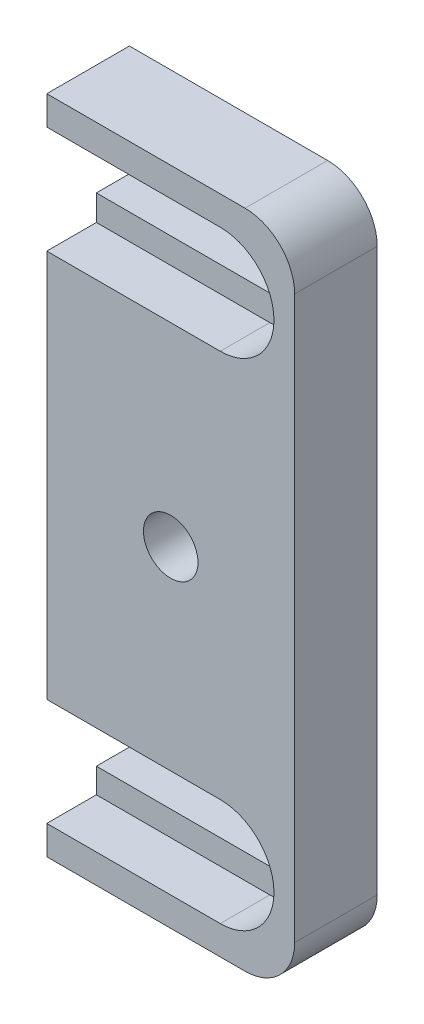
from build123d import *

# Parameters (mm, degrees)
SKETCH1_W                 = 15
SKETCH1_H                 = 40
BOSS_EXTRUDE1_DEPTH       = 5
CUT_EXTRUDE1_DEPTH        = 3
CUT_EXTRUDE2_DEPTH        = 3
CUT_EXTRUDE3_DEPTH        = 3
CUT_EXTRUDE4_DEPTH        = 6
F_4_CLEARANCE_HOLE1_D     = 3.3
F_4_CLEARANCE_HOLE1_DEPTH = 5
FILLET1_R                 = 3


with BuildPart() as part:
    # Sketch1 → Boss-Extrude1 (new body)
    with BuildSketch(Plane.XY.offset(5)):
        with Locations((7.5, -20)):
            Rectangle(SKETCH1_W, SKETCH1_H)
    extrude(amount=-BOSS_EXTRUDE1_DEPTH)

    # Sketch2 → Cut-Extrude1 (cut)
    with BuildSketch(Plane.XY.offset(5)):
        with BuildLine():
            Line((0, -8.25), (10.5, -8.25))
            ThreePointArc((10.5, -8.25), (13.75, -5), (10.5, -1.75))
            Line((10.5, -1.75), (0, -1.75))
            Line((0, -1.75), (0, -8.25))
        make_face()
    extrude(amount=-CUT_EXTRUDE1_DEPTH, mode=Mode.SUBTRACT)

    # Sketch3 → Cut-Extrude2 (cut, through all)
    with BuildSketch(Plane.XY.offset(2)):
        with BuildLine():
            Line((0, -3.3), (0, -6.7))
            Line((0, -6.7), (10.5, -6.7))
            ThreePointArc((10.5, -6.7), (12.2, -5), (10.5, -3.3))
            Line((10.5, -3.3), (0, -3.3))
        make_face()
    extrude(amount=-CUT_EXTRUDE2_DEPTH, mode=Mode.SUBTRACT)

    # Sketch4 → Cut-Extrude3 (cut)
    with BuildSketch(Plane.XY.offset(5)):
        with BuildLine():
            Line((0, -38.25), (10.5, -38.25))
            ThreePointArc((10.5, -38.25), (13.75, -35), (10.5, -31.75))
            Line((10.5, -31.75), (0, -31.75))
            Line((0, -31.75), (0, -38.25))
        make_face()
    extrude(amount=-CUT_EXTRUDE3_DEPTH, mode=Mode.SUBTRACT)

    # Sketch5 → Cut-Extrude4 (cut, through all)
    with BuildSketch(Plane(origin=(0, 0, 0), x_dir=(-1, 0, 0), z_dir=(0, 0, -1))):
        with BuildLine():
            Line((0, -36.75), (0, -33.25))
            Line((0, -33.25), (-10.5, -33.25))
            ThreePointArc((-10.5, -33.25), (-12.25, -35), (-10.5, -36.75))
            Line((-10.5, -36.75), (0, -36.75))
        make_face()
    extrude(amount=-CUT_EXTRUDE4_DEPTH, mode=Mode.SUBTRACT)

    # #4 Clearance Hole1
    with Locations(Plane.XY.offset(5)):
        with Locations((7.5, -20)):
            Hole(F_4_CLEARANCE_HOLE1_D / 2, depth=F_4_CLEARANCE_HOLE1_DEPTH)

    # Fillet1
    fillet1_edges = [part.edges().sort_by_distance(p)[0] for p in [
        (15, -40, 2.5),
        (15, 0, 2.5),
    ]]
    fillet(fillet1_edges, radius=FILLET1_R)


solid = part.part
